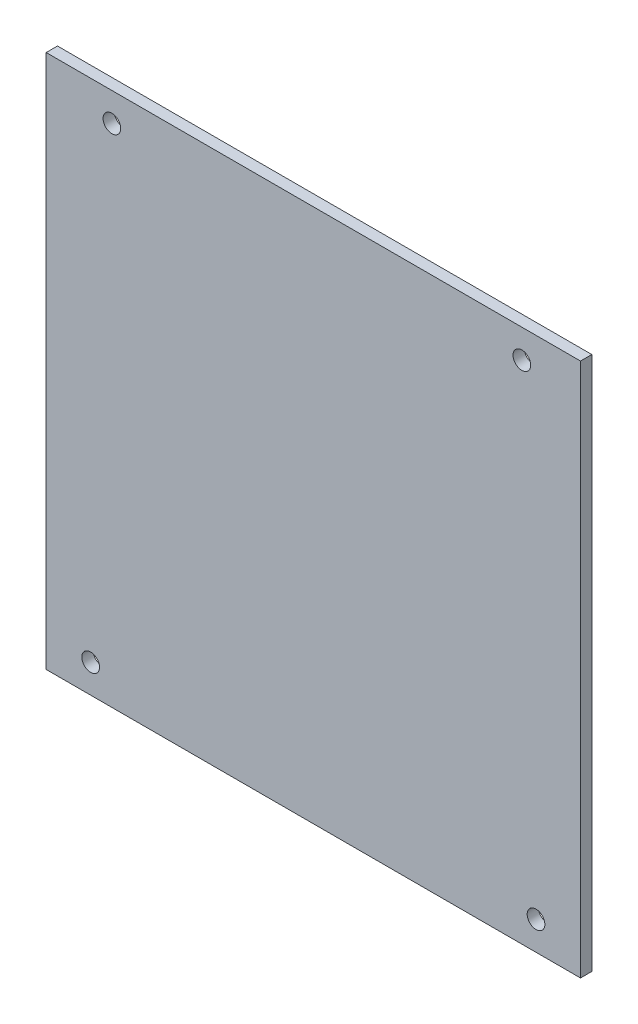
from build123d import *

# Parameters (mm, degrees)
SKETCH3_W           = 96
SKETCH3_H           = 96
SKETCH3_R           = 1.59
BOSS_EXTRUDE1_DEPTH = 1.016


with BuildPart() as part:
    # Sketch3 → Boss-Extrude1 (new body, symmetric)
    with BuildSketch(Plane.XY):
        Rectangle(SKETCH3_W, SKETCH3_H)
        with Locations((40.005, -42.865)):
            Circle(SKETCH3_R, mode=Mode.SUBTRACT)
        with Locations((37.465, 42.865)):
            Circle(SKETCH3_R, mode=Mode.SUBTRACT)
        with Locations((-36.195, 42.865)):
            Circle(SKETCH3_R, mode=Mode.SUBTRACT)
        with Locations((-40.005, -42.865)):
            Circle(SKETCH3_R, mode=Mode.SUBTRACT)
    extrude(amount=BOSS_EXTRUDE1_DEPTH, both=True)


solid = part.part
